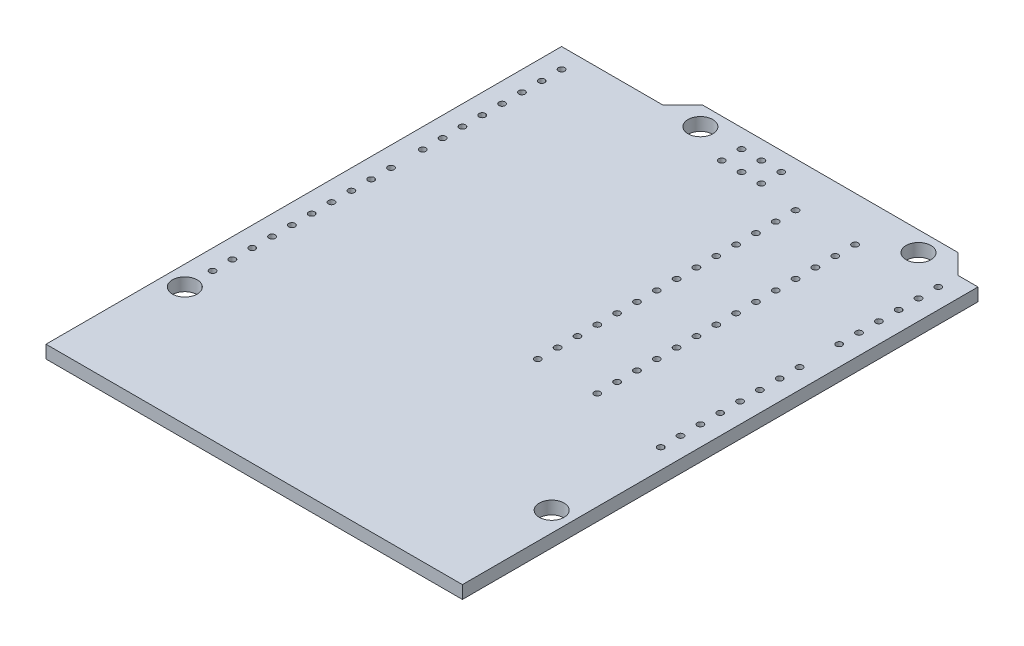
from build123d import *

# Parameters (mm, degrees)
SKETCH1_R           = 1.5875
BOSS_EXTRUDE1_DEPTH = 1.65
SKETCH2_R           = 0.4
CUT_EXTRUDE1_DEPTH  = 1.65
SKETCH3_R           = 0.4
CUT_EXTRUDE2_DEPTH  = 1.65
LPATTERN1_COUNT     = 15
LPATTERN1_PITCH     = 2.54
SKETCH4_R           = 0.4
CUT_EXTRUDE3_DEPTH  = 1.65
LPATTERN2_COUNT     = 10
LPATTERN2_PITCH     = 2.54
LPATTERN3_COUNT     = 8
LPATTERN3_PITCH     = 2.54
SKETCH5_R           = 0.4
SKETCH5_R_2         = 0.5
CUT_EXTRUDE4_DEPTH  = 10
SKETCH6_R           = 0.4
CUT_EXTRUDE5_DEPTH  = 10


with BuildPart() as part:
    # Sketch1 → Boss-Extrude1 (new body)
    with BuildSketch(Plane(origin=(0, 0, 0), x_dir=(1, 0, 0), z_dir=(0, 1, 0))):
        Polygon((0, 0), (-53.34, 0), (-53.34, 66.04), (-40.386, 66.04), (-37.846, 68.58), (-5.08, 68.58), (-2.54, 66.04), (0, 66.04), align=None)
        with Locations((-7.62, 66.04)):
            Circle(SKETCH1_R, mode=Mode.SUBTRACT)
        with Locations((-35.56, 66.04)):
            Circle(SKETCH1_R, mode=Mode.SUBTRACT)
        with Locations((-2.54, 13.97)):
            Circle(SKETCH1_R, mode=Mode.SUBTRACT)
        with Locations((-50.8, 15.24)):
            Circle(SKETCH1_R, mode=Mode.SUBTRACT)
    extrude(amount=-BOSS_EXTRUDE1_DEPTH)

    # Sketch2 → Cut-Extrude1 (cut)
    with BuildSketch(Plane(origin=(0, 0, 0), x_dir=(1, 0, 0), z_dir=(0, 1, 0))):
        with Locations((-2.54, 27.94)):
            Circle(SKETCH2_R)
    cut_extrude1 = extrude(amount=-CUT_EXTRUDE1_DEPTH, mode=Mode.SUBTRACT)

    # Sketch3 → Cut-Extrude2 (cut)
    with BuildSketch(Plane(origin=(0, 0, 0), x_dir=(1, 0, 0), z_dir=(0, 1, 0))):
        with Locations((-50.8, 18.796)):
            Circle(SKETCH3_R)
    cut_extrude2 = extrude(amount=-CUT_EXTRUDE2_DEPTH, mode=Mode.SUBTRACT)

    # LPattern1: Cut-Extrude1 ×15, 1 skipped
    with Locations(*[(0, 0, -i * LPATTERN1_PITCH) for i in range(1, LPATTERN1_COUNT) if i not in (8,)]):
        add(cut_extrude1, mode=Mode.SUBTRACT)

    # Sketch4 → Cut-Extrude3 (cut)
    with BuildSketch(Plane(origin=(0, 0, 0), x_dir=(1, 0, 0), z_dir=(0, 1, 0))):
        with Locations((-50.8, 45.72)):
            Circle(SKETCH4_R)
    cut_extrude3 = extrude(amount=-CUT_EXTRUDE3_DEPTH, mode=Mode.SUBTRACT)

    # LPattern2: Cut-Extrude2 ×10
    with Locations(*[(0, 0, -i * LPATTERN2_PITCH) for i in range(1, LPATTERN2_COUNT)]):
        add(cut_extrude2, mode=Mode.SUBTRACT)

    # LPattern3: Cut-Extrude3 ×8
    with Locations(*[(0, 0, -i * LPATTERN3_PITCH) for i in range(1, LPATTERN3_COUNT)]):
        add(cut_extrude3, mode=Mode.SUBTRACT)

    # Sketch5 → Cut-Extrude4 (cut)
    with BuildSketch(Plane(origin=(0, 0, 0), x_dir=(1, 0, 0), z_dir=(0, 1, 0))):
        with Locations((-30.43, 66.18)):
            Circle(SKETCH5_R)
        with Locations((-27.89, 66.18)):
            Circle(SKETCH5_R)
        with Locations((-25.35, 66.18)):
            Circle(SKETCH5_R)
        with Locations((-25.35, 63.64)):
            Circle(SKETCH5_R)
        with Locations((-27.89, 63.64)):
            Circle(SKETCH5_R)
        with Locations((-30.43, 63.64)):
            Circle(SKETCH5_R)
        with Locations((-47.498, 399.9992)):
            Circle(SKETCH5_R)
        with Locations((-47.498, 402.5392)):
            Circle(SKETCH5_R)
        with Locations((-47.498, 405.0792)):
            Circle(SKETCH5_R)
        with Locations((-44.958, 405.0792)):
            Circle(SKETCH5_R)
        with Locations((-44.958, 402.5392)):
            Circle(SKETCH5_R)
        with Locations((-44.958, 399.9992)):
            Circle(SKETCH5_R)
        with Locations((-42.418, 402.5392)):
            Circle(SKETCH5_R)
        with Locations((-42.418, 405.0792)):
            Circle(SKETCH5_R)
        with Locations((-39.878, 405.0792)):
            Circle(SKETCH5_R)
        with Locations((-39.878, 402.5392)):
            Circle(SKETCH5_R)
        with Locations((-26.162, 421.2082)):
            Circle(SKETCH5_R_2)
        with Locations((-26.162, 416.1282)):
            Circle(SKETCH5_R_2)
    extrude(amount=-CUT_EXTRUDE4_DEPTH, mode=Mode.SUBTRACT)

    # Sketch6 → Cut-Extrude5 (cut)
    with BuildSketch(Plane(origin=(0, 0, 0), x_dir=(1, 0, 0), z_dir=(0, 1, 0))):
        with Locations((-20.193, 29.845)):
            Circle(SKETCH6_R)
        with Locations((-12.573, 29.845)):
            Circle(SKETCH6_R)
        with Locations((-20.193, 32.385)):
            Circle(SKETCH6_R)
        with Locations((-12.573, 32.385)):
            Circle(SKETCH6_R)
        with Locations((-20.193, 34.925)):
            Circle(SKETCH6_R)
        with Locations((-12.573, 34.925)):
            Circle(SKETCH6_R)
        with Locations((-20.193, 37.465)):
            Circle(SKETCH6_R)
        with Locations((-12.573, 37.465)):
            Circle(SKETCH6_R)
        with Locations((-20.193, 40.005)):
            Circle(SKETCH6_R)
        with Locations((-12.573, 40.005)):
            Circle(SKETCH6_R)
        with Locations((-20.193, 42.545)):
            Circle(SKETCH6_R)
        with Locations((-12.573, 42.545)):
            Circle(SKETCH6_R)
        with Locations((-20.193, 45.085)):
            Circle(SKETCH6_R)
        with Locations((-12.573, 45.085)):
            Circle(SKETCH6_R)
        with Locations((-20.193, 47.625)):
            Circle(SKETCH6_R)
        with Locations((-12.573, 47.625)):
            Circle(SKETCH6_R)
        with Locations((-20.193, 50.165)):
            Circle(SKETCH6_R)
        with Locations((-12.573, 50.165)):
            Circle(SKETCH6_R)
        with Locations((-20.193, 52.705)):
            Circle(SKETCH6_R)
        with Locations((-12.573, 52.705)):
            Circle(SKETCH6_R)
        with Locations((-20.193, 55.245)):
            Circle(SKETCH6_R)
        with Locations((-12.573, 55.245)):
            Circle(SKETCH6_R)
        with Locations((-20.193, 57.785)):
            Circle(SKETCH6_R)
        with Locations((-12.573, 57.785)):
            Circle(SKETCH6_R)
        with Locations((-20.193, 60.325)):
            Circle(SKETCH6_R)
        with Locations((-12.573, 60.325)):
            Circle(SKETCH6_R)
        with Locations((-20.193, 62.865)):
            Circle(SKETCH6_R)
        with Locations((-12.573, 62.865)):
            Circle(SKETCH6_R)
    extrude(amount=-CUT_EXTRUDE5_DEPTH, mode=Mode.SUBTRACT)


solid = part.part
